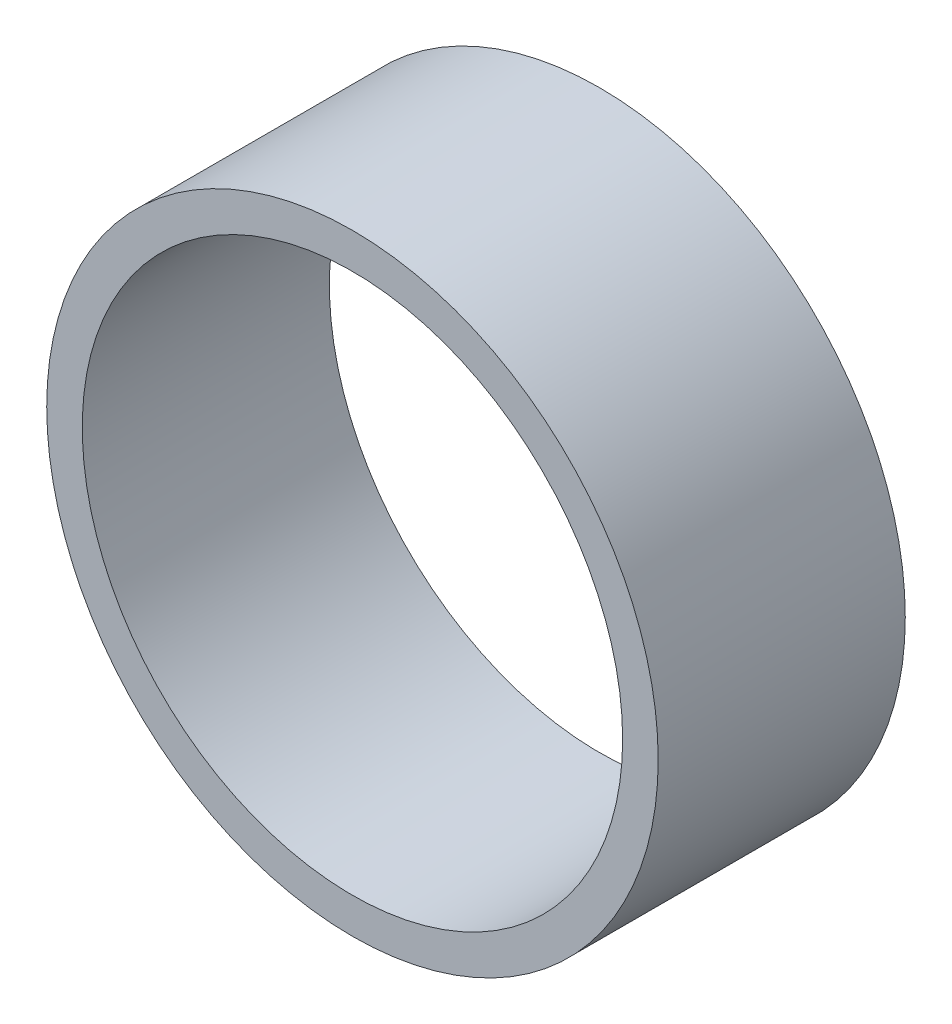
from build123d import *

# Parameters (mm, degrees)
SKETCH1_R           = 86
SKETCH1_R_2         = 76
BOSS_EXTRUDE1_DEPTH = 69.5


with BuildPart() as part:
    # Sketch1 → Boss-Extrude1 (new body)
    with BuildSketch(Plane.XY):
        Circle(SKETCH1_R)
        Circle(SKETCH1_R_2, mode=Mode.SUBTRACT)
    extrude(amount=BOSS_EXTRUDE1_DEPTH)


solid = part.part
